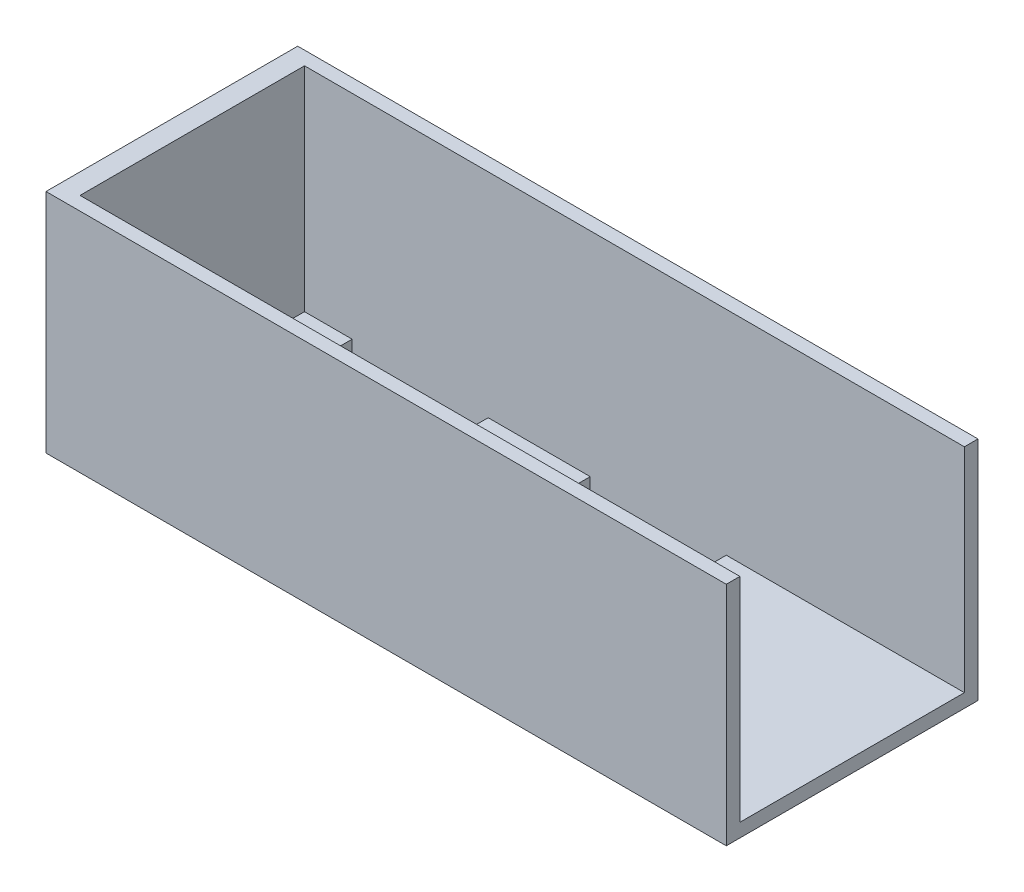
from build123d import *

# Parameters (mm, degrees)
BOSS_EXTRUDE1_DEPTH = 50
SKETCH2_W           = 37
SKETCH2_H           = 33.3
BOSS_EXTRUDE2_DEPTH = 3
SKETCH3_W           = 20
SKETCH3_H           = 7
CUT_EXTRUDE1_DEPTH  = 50


with BuildPart() as part:
    # Sketch1 → Boss-Extrude1 (new body, symmetric)
    with BuildSketch(Plane(origin=(0, 0, 0), x_dir=(0, 0, -1), z_dir=(1, 0, 0))):
        Polygon((16, 0), (18, 0), (18, -33.3), (-19, -33.3), (-19, 0), (-17, 0), (-17, -31.3), (16, -31.3), align=None)
    extrude(amount=BOSS_EXTRUDE1_DEPTH, both=True)

    # Sketch2 → Boss-Extrude2 (add)
    with BuildSketch(Plane.ZY.offset(50)):
        with Locations((0.5, -16.65)):
            Rectangle(SKETCH2_W, SKETCH2_H)
    extrude(amount=-BOSS_EXTRUDE2_DEPTH)

    # Sketch3 → Cut-Extrude1 (cut)
    with BuildSketch(Plane(origin=(0, 0, 0), x_dir=(1, 0, 0), z_dir=(0, 1, 0))):
        with Locations((-30, -13.5)):
            Rectangle(SKETCH3_W, SKETCH3_H)
        with Locations((5, -13.5)):
            Rectangle(SKETCH3_W, SKETCH3_H)
        with Locations((-30, 12.5)):
            Rectangle(SKETCH3_W, SKETCH3_H)
        with Locations((5, 12.5)):
            Rectangle(SKETCH3_W, SKETCH3_H)
    extrude(amount=-CUT_EXTRUDE1_DEPTH, mode=Mode.SUBTRACT)


solid = part.part
